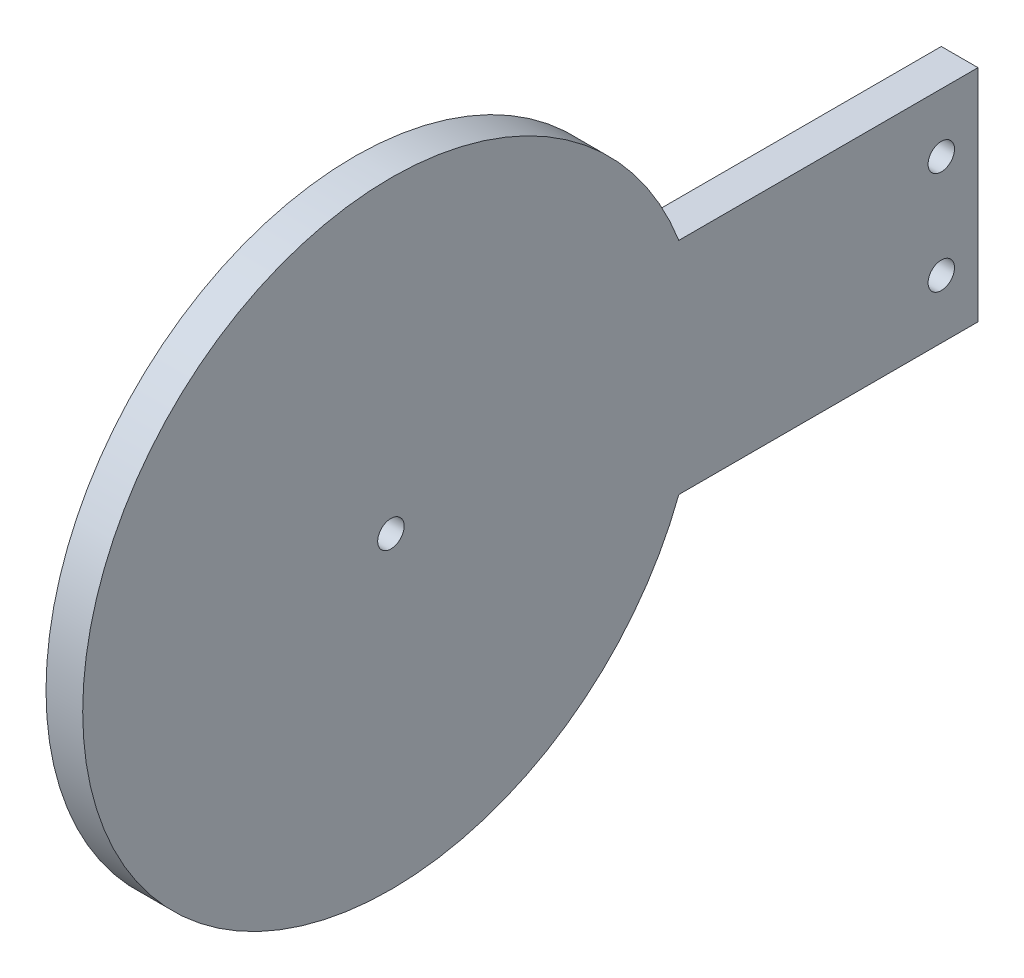
from build123d import *

# Parameters (mm, degrees)
EXTRUDE_1_DEPTH     = 2.5
SKETCH_2_R          = 0.9
CUT_EXTRUDE_1_DEPTH = 3.5


with BuildPart() as part:
    # 스케치1 → 보스-돌출1 (new body)
    with BuildSketch(Plane(origin=(-9, 0, 0), x_dir=(0, -1, 0), z_dir=(-1, 0, 0))):
        with BuildLine():
            Line((-21, -18.122865071), (-21, 2.262089683))
            ThreePointArc((-21, 2.262089683), (-13.5, 42.877134929), (-6, 2.262089683))
            Line((-6, 2.262089683), (-6, -18.122865071))
            Line((-6, -18.122865071), (-21, -18.122865071))
        make_face()
    extrude(amount=-EXTRUDE_1_DEPTH)

    # 스케치2 → 컷-돌출1 (cut, through all)
    with BuildSketch(Plane(origin=(-6.5, 0, 0), x_dir=(0, 0, -1), z_dir=(1, 0, 0))):
        with Locations((15.622865071, 10)):
            Circle(SKETCH_2_R)
        with Locations((15.622865071, 17)):
            Circle(SKETCH_2_R)
        with Locations((-21.877134929, 13.5)):
            Circle(SKETCH_2_R)
    extrude(amount=-CUT_EXTRUDE_1_DEPTH, mode=Mode.SUBTRACT)


solid = part.part
